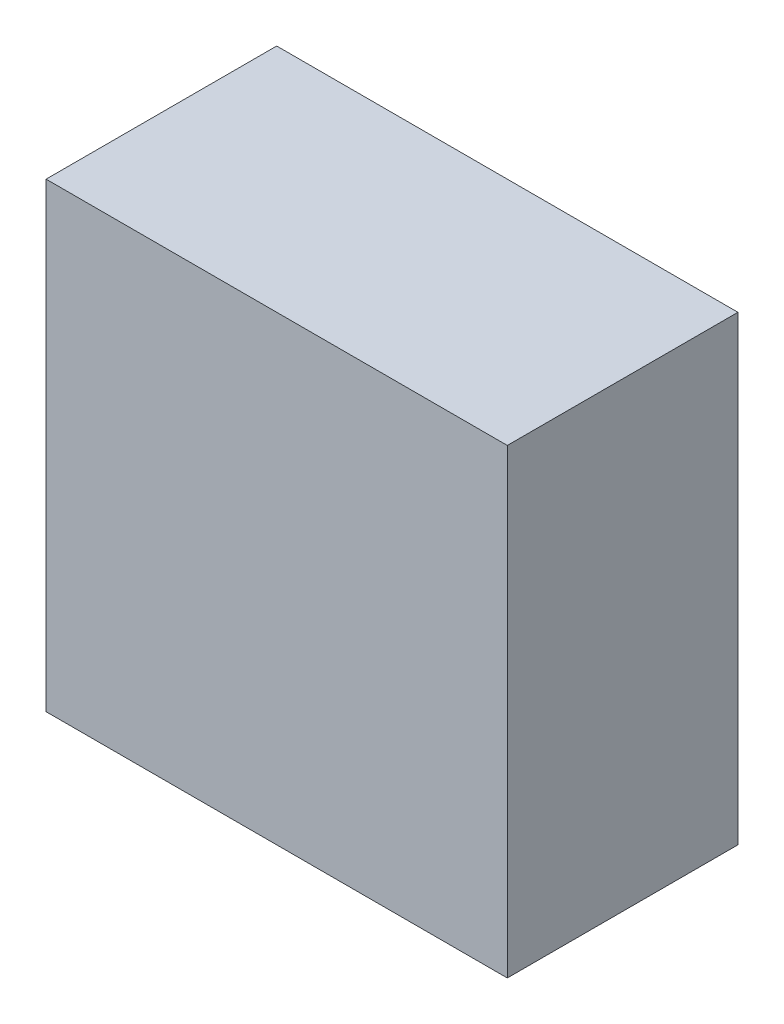
from build123d import *

# Parameters (mm, degrees)
SKETCH_1_W      = 40
SKETCH_1_H      = 40
EXTRUDE_1_DEPTH = 20


with BuildPart() as part:
    # 草图1 → 凸台-拉伸1 (new body)
    with BuildSketch(Plane.XY):
        Rectangle(SKETCH_1_W, SKETCH_1_H)
    extrude(amount=EXTRUDE_1_DEPTH)


solid = part.part
